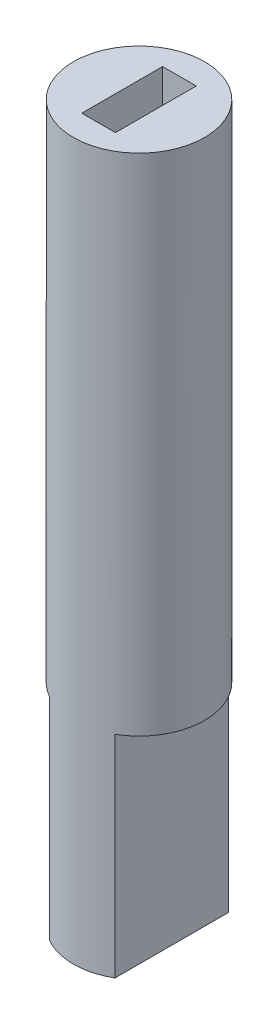
from build123d import *

# Parameters (mm, degrees)
SKETCH1_R               = 30
BOSS_EXTRUDE1_DEPTH     = 200
BOSS_EXTRUDE2_START     = -60
SKETCH2_R               = 4
BOSS_EXTRUDE2_DEPTH     = 80
BOSS_EXTRUDE3_DEPTH     = 10
BOSS_EXTRUDE4_DEPTH     = 10
FILLET1_R               = 10
FILLET2_R               = 3
CUT_EXTRUDE1_START      = -34
SKETCH7_R               = 4
CUT_EXTRUDE1_DEPTH      = 12
SKETCH8_R               = 2
CUT_EXTRUDE2_DEPTH      = 70
BOSS_EXTRUDE6_START     = 0.1
SKETCH9_R               = 2
BOSS_EXTRUDE6_DEPTH     = 70
CUT_EXTRUDE4_START      = -30
CUT_EXTRUDE4_DEPTH      = 35
SKETCH12_W              = 1
SKETCH12_H              = 2.4
CUT_EXTRUDE5_DEPTH      = 20
CUT_EXTRUDE6_START      = -200
SKETCH14_R              = 30
CUT_EXTRUDE6_DEPTH      = 200
SKETCH15_R              = 97.689585443
SKETCH15_R_2            = 2
CUT_EXTRUDE7_DEPTH      = 200
CUT_EXTRUDE8_DEPTH      = 200
CUT_EXTRUDE8_DEPTH_BACK = 200
SKETCH16_W              = 5.14946919
SKETCH16_H              = 11.525449866
CUT_EXTRUDE9_DEPTH      = 200
CUT_EXTRUDE9_DEPTH_BACK = 200
SKETCH17_W              = 4
SKETCH17_H              = 5
SKETCH19_W              = 8.073982183
SKETCH19_H              = 13.216207409
CUT_EXTRUDE11_DEPTH     = 7
SKETCH20_W              = 16.90925267
SKETCH20_H              = 17.799092854
CUT_EXTRUDE12_DEPTH     = 3
SKETCH21_W              = 18.708797059
SKETCH21_H              = 16.020174298
CUT_EXTRUDE13_DEPTH     = 3
SKETCH22_W              = 8.604903729
SKETCH22_H              = 5.934872157
CUT_EXTRUDE14_DEPTH     = 30.73
CUT_EXTRUDE15_DEPTH     = 5
SKETCH24_R              = 2
SKETCH24_R_2            = 1.95
CUT_EXTRUDE16_DEPTH     = 25


with BuildPart() as part:
    # Sketch1 → Boss-Extrude1 (new body)
    with BuildSketch(Plane(origin=(0, 0, 0), x_dir=(1, 0, 0), z_dir=(0, 1, 0))):
        Circle(SKETCH1_R)
    extrude(amount=BOSS_EXTRUDE1_DEPTH)

    # Sketch14 → Cut-Extrude6 (cut)
    with BuildSketch(Plane(origin=(0, 200, 0), x_dir=(1, 0, 0), z_dir=(0, 1, 0)).offset(CUT_EXTRUDE6_START)):
        Circle(SKETCH14_R)
    extrude(amount=CUT_EXTRUDE6_DEPTH, mode=Mode.SUBTRACT)


with BuildPart() as body_2:
    # Sketch2 → Boss-Extrude2 (new body)
    with BuildSketch(Plane(origin=(0, 200, 0), x_dir=(1, 0, 0), z_dir=(0, 1, 0)).offset(BOSS_EXTRUDE2_START)):
        with Locations((0, -50)):
            Circle(SKETCH2_R)
    extrude(amount=-BOSS_EXTRUDE2_DEPTH)

    # Sketch4 → Boss-Extrude3 (add)
    with BuildSketch(Plane(origin=(0, 140, 0), x_dir=(1, 0, 0), z_dir=(0, 1, 0))):
        with BuildLine():
            Line((-2.932848445, -47.28), (40.915854419, 0))
            Line((40.915854419, 0), (6, 37.648128431))
            Line((6, 37.648128431), (11.86569689, 43.088128431))
            Line((11.86569689, 43.088128431), (51.826748931, 0))
            Line((51.826748931, 0), (2.932848445, -52.72))
            ThreePointArc((2.932848445, -52.72), (2.72, -47.067151555), (-2.932848445, -47.28))
        make_face()
    extrude(amount=-BOSS_EXTRUDE3_DEPTH)

    # Sketch5 → Boss-Extrude4 (add)
    with BuildSketch(Plane.XZ.offset(-60)):
        with BuildLine():
            Line((6, -37.648128431), (11.86569689, -43.088128431))
            Line((11.86569689, -43.088128431), (51.826748931, 0))
            Line((51.826748931, 0), (2.932848445, 52.72))
            ThreePointArc((2.932848445, 52.72), (2.72, 47.067151555), (-2.932848445, 47.28))
            Line((-2.932848445, 47.28), (40.915854419, 0))
            Line((40.915854419, 0), (6, -37.648128431))
        make_face()
    extrude(amount=-BOSS_EXTRUDE4_DEPTH)

    # Fillet1
    fillet1_edges = [body_2.edges().sort_by_distance(p)[0] for p in [
        (51.826748931, 65, 0),
        (40.915854419, 65, 0),
        (40.915854419, 135, 0),
        (51.826748931, 135, 0),
    ]]
    fillet(fillet1_edges, radius=FILLET1_R)

    # Fillet2
    fillet2_edges = [body_2.edges().sort_by_distance(p)[0] for p in [
        (11.86569689, 65, -43.088128431),
        (8.932848445, 70, -40.368128431),
        (6, 65, -37.648128431),
        (8.932848445, 60, -40.368128431),
        (6, 135, -37.648128431),
        (8.932848445, 130, -40.368128431),
        (11.86569689, 135, -43.088128431),
        (8.932848445, 140, -40.368128431),
    ]]
    fillet(fillet2_edges, radius=FILLET2_R)

    # Sketch7 → Cut-Extrude1 (cut)
    with BuildSketch(Plane(origin=(0, 140, 0), x_dir=(1, 0, 0), z_dir=(0, 1, 0)).offset(CUT_EXTRUDE1_START)):
        with Locations((0, -50)):
            Circle(SKETCH7_R)
    extrude(amount=-CUT_EXTRUDE1_DEPTH, mode=Mode.SUBTRACT)


with BuildPart() as cut_extrude1_piece_1:
    # of the separate pieces the step leaves, piece 1, a body of its own (cut_extrude1_pieces)
    add(body_2.part.solids().sort_by_distance((13.90569689, 70, -40.888492097))[0])


with BuildPart() as cut_extrude1_piece_2:
    # of the separate pieces the step leaves, piece 2, a body of its own (cut_extrude1_pieces)
    add(body_2.part.solids().sort_by_distance((4, 130, 50))[0])


with BuildPart() as cut_extrude2_tool:
    # Sketch8 → Cut-Extrude2 (new body)
    with BuildSketch(Plane(origin=(0, 140, 0), x_dir=(1, 0, 0), z_dir=(0, 1, 0))):
        with Locations((0, -50)):
            Circle(SKETCH8_R)
    extrude(amount=-CUT_EXTRUDE2_DEPTH)


with BuildPart() as cut_extrude1_piece_1_1:
    add(cut_extrude1_piece_1.part)

    # Cut-Extrude2: cut by cut_extrude2_tool
    add(cut_extrude2_tool.part, mode=Mode.SUBTRACT)



with BuildPart() as cut_extrude1_piece_2_1:
    add(cut_extrude1_piece_2.part)

    # Cut-Extrude2: cut by cut_extrude2_tool
    add(cut_extrude2_tool.part, mode=Mode.SUBTRACT)


with BuildPart() as cut_extrude1_piece_1_2:
    add(cut_extrude1_piece_1_1.part)

    add(cut_extrude1_piece_2_1.part)  # Boss-Extrude6 merges Cut-Extrude1 piece 2
    # Sketch9 → Boss-Extrude6 (add)
    with BuildSketch(Plane(origin=(0, 140, 0), x_dir=(1, 0, 0), z_dir=(0, 1, 0)).offset(BOSS_EXTRUDE6_START)):
        with Locations((0, -50)):
            Circle(SKETCH9_R)
    extrude(amount=-BOSS_EXTRUDE6_DEPTH)

    # Sketch11 → Cut-Extrude4 (cut)
    with BuildSketch(Plane(origin=(0, 140.1, 0), x_dir=(1, 0, 0), z_dir=(0, 1, 0)).offset(CUT_EXTRUDE4_START)):
        with BuildLine():
            Line((-0.975, -51.746245974), (-0.975, -48.253754026))
            ThreePointArc((-0.975, -48.253754026), (-2, -50), (-0.975, -51.746245974))
        make_face()
        with BuildLine():
            Line((0.975, -48.253754026), (0.975, -51.746245974))
            ThreePointArc((0.975, -51.746245974), (2, -50), (0.975, -48.253754026))
        make_face()
    extrude(amount=-CUT_EXTRUDE4_DEPTH, mode=Mode.SUBTRACT)

    # Sketch12 → Cut-Extrude5 (cut)
    with BuildSketch(Plane(origin=(0, 140.1, 0), x_dir=(1, 0, 0), z_dir=(0, 1, 0))):
        with Locations((0, -50)):
            Rectangle(SKETCH12_W, SKETCH12_H)
    extrude(amount=-CUT_EXTRUDE5_DEPTH, mode=Mode.SUBTRACT)

    # Sketch15 → Cut-Extrude7 (cut)
    with BuildSketch(Plane(origin=(0, 140, 0), x_dir=(1, 0, 0), z_dir=(0, 1, 0))):
        with Locations((0, -50)):
            Circle(SKETCH15_R)
        with Locations((0, -50)):
            Circle(SKETCH15_R_2, mode=Mode.SUBTRACT)
    extrude(amount=-CUT_EXTRUDE7_DEPTH, mode=Mode.SUBTRACT)


with BuildPart() as cut_extrude7_piece_1:
    # of the separate pieces the step leaves, piece 1, a body of its own (cut_extrude7_pieces)
    add(cut_extrude1_piece_1_2.part.solids().sort_by_distance((0.975, 110.1, 51.746245974))[0])

    # Sketch17 → Cut-Extrude9 (cut, two sides: drawn at the far end of the back side and taken through both)
    with BuildSketch(Plane.ZY.offset(0.975).offset(-CUT_EXTRUDE9_DEPTH_BACK)):
        with Locations((50, 72.6)):
            Rectangle(SKETCH17_W, SKETCH17_H)
    extrude(amount=CUT_EXTRUDE9_DEPTH + CUT_EXTRUDE9_DEPTH_BACK, mode=Mode.SUBTRACT)

    # Sketch19 → Cut-Extrude11 (cut)
    with BuildSketch(Plane(origin=(0, 140.1, 0), x_dir=(1, 0, 0), z_dir=(0, 1, 0))):
        with Locations((-1.711492601, -47.464499481)):
            Rectangle(SKETCH19_W, SKETCH19_H)
    extrude(amount=-CUT_EXTRUDE11_DEPTH, mode=Mode.SUBTRACT)

    # Sketch20 → Cut-Extrude12 (cut)
    with BuildSketch(Plane(origin=(0, 133.1, 0), x_dir=(1, 0, 0), z_dir=(0, 1, 0))):
        with Locations((1.357922153, -50.543868256)):
            Rectangle(SKETCH20_W, SKETCH20_H)
    extrude(amount=-CUT_EXTRUDE12_DEPTH, mode=Mode.SUBTRACT)

    # Sketch21 → Cut-Extrude13 (cut)
    with BuildSketch(Plane.XZ.offset(-75.1)):
        with Locations((-2.026585117, 52.503315088)):
            Rectangle(SKETCH21_W, SKETCH21_H)
    extrude(amount=-CUT_EXTRUDE13_DEPTH, mode=Mode.SUBTRACT)

    # Sketch22 → Cut-Extrude14 (cut)
    with BuildSketch(Plane.XZ.offset(-78.1)):
        with Locations((0.059480902, 50.237923606)):
            Rectangle(SKETCH22_W, SKETCH22_H)
    extrude(amount=-CUT_EXTRUDE14_DEPTH, mode=Mode.SUBTRACT)

    # Sketch23 → Cut-Extrude15 (cut)
    with BuildSketch(Plane.XZ.offset(-110.1)):
        with BuildLine():
            Line((-0.975, 51.746245974), (-0.975, 48.253754026))
            ThreePointArc((-0.975, 48.253754026), (-2, 50), (-0.975, 51.746245974))
        make_face()
        with BuildLine():
            Line((0.975, 48.253754026), (0.975, 51.746245974))
            ThreePointArc((0.975, 51.746245974), (2, 50), (0.975, 48.253754026))
        make_face()
    extrude(amount=-CUT_EXTRUDE15_DEPTH, mode=Mode.SUBTRACT)

    # Sketch24 → Cut-Extrude16 (cut)
    with BuildSketch(Plane(origin=(0, 130.1, 0), x_dir=(1, 0, 0), z_dir=(0, 1, 0))):
        with Locations((0, -50)):
            Circle(SKETCH24_R)
        with Locations((0, -50)):
            Circle(SKETCH24_R_2, mode=Mode.SUBTRACT)
    extrude(amount=-CUT_EXTRUDE16_DEPTH, mode=Mode.SUBTRACT)


with BuildPart() as cut_extrude7_piece_2:
    # of the separate pieces the step leaves, piece 2, a body of its own (cut_extrude7_pieces)
    add(cut_extrude1_piece_1_2.part.solids().sort_by_distance((2, 60, 50))[0])

    # Sketch16 → Cut-Extrude8 (cut, two sides: drawn at the far end of the back side and taken through both)
    with BuildSketch(Plane(origin=(0.975, 0, 0), x_dir=(0, 0, -1), z_dir=(1, 0, 0)).offset(-CUT_EXTRUDE8_DEPTH_BACK)):
        with Locations((-49.425265405, 64.237275067)):
            Rectangle(SKETCH16_W, SKETCH16_H)
    extrude(amount=CUT_EXTRUDE8_DEPTH + CUT_EXTRUDE8_DEPTH_BACK, mode=Mode.SUBTRACT)


solid = cut_extrude7_piece_1.part
